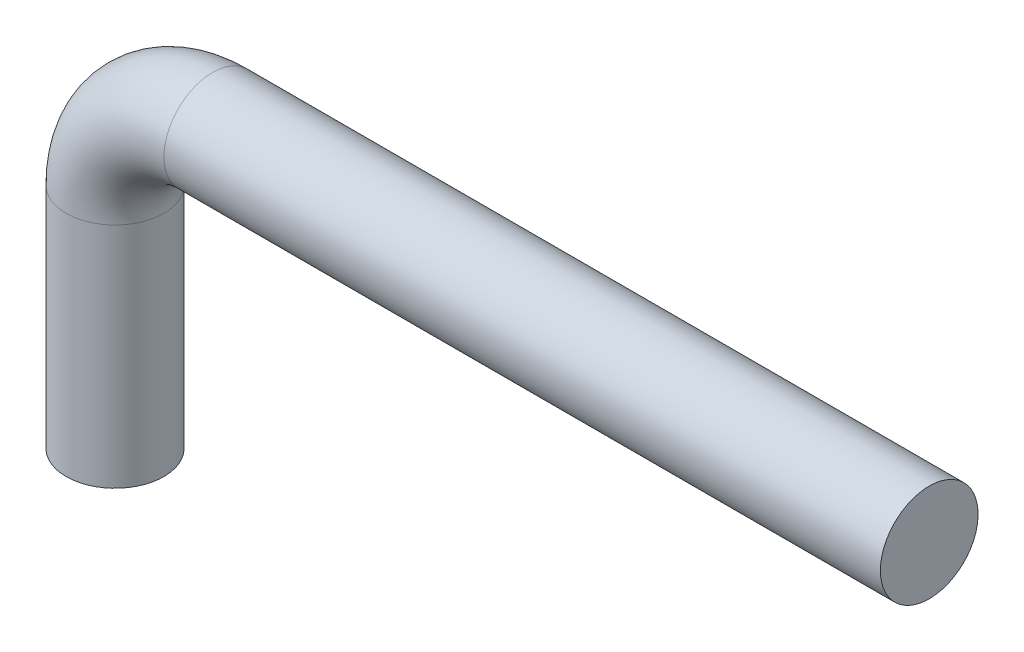
from build123d import *

# Parameters (mm, degrees)
SWEEP1_PROFILE_R = 3.81


with BuildPart() as part:
    # Sweep1: sweep along a path in Sketch1
    with BuildLine(Plane.XY) as sweep1_path:
        Line((42.19269103, 25.948504983), (-13.68730897, 25.948504983))
        ThreePointArc((-13.68730897, 25.948504983), (-19.075462643, 23.716658656), (-21.30730897, 18.328504983))
        Line((-21.30730897, 18.328504983), (-21.30730897, 0.548504983))
    # Sweep1 profile (on start of the path) → Sweep1 (sweep)
    with BuildSketch(Plane(origin=(42.19269103, 25.948504983, 0), x_dir=(0, 0, -1), z_dir=(-1, 0, 0))):
        Circle(SWEEP1_PROFILE_R)
    sweep(path=sweep1_path.line)


solid = part.part
